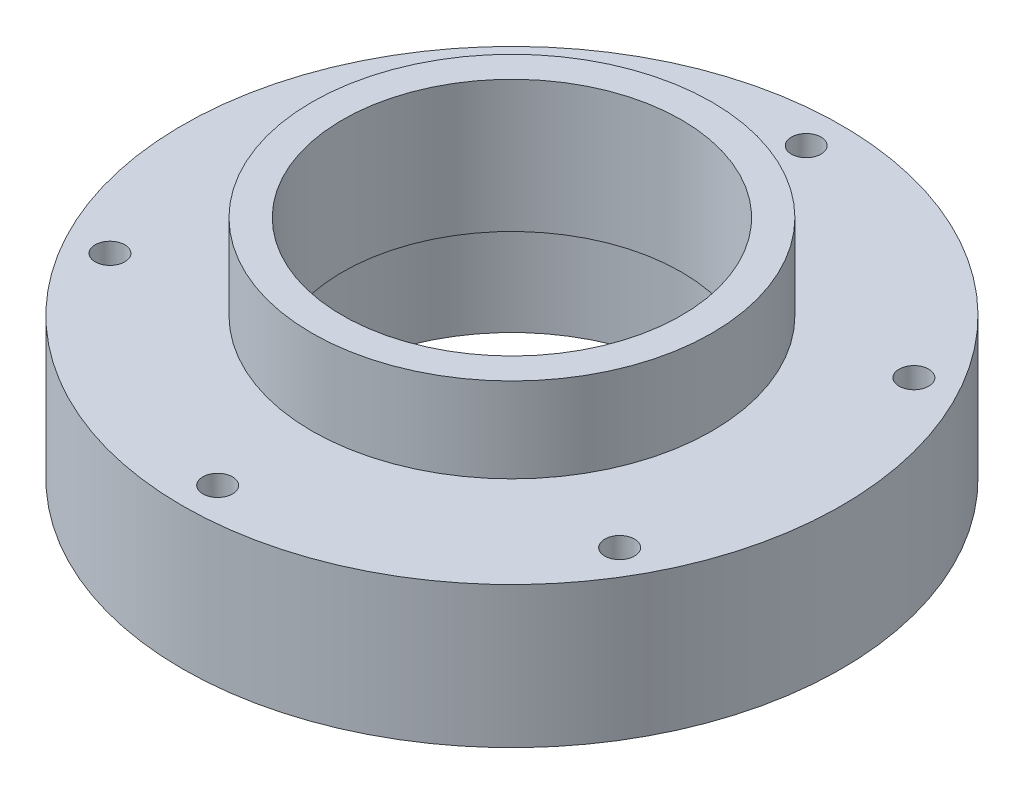
from build123d import *

# Parameters (mm, degrees)
SKETCH1_R                               = 17.78
BOSS_EXTRUDE1_DEPTH                     = 7.62
SKETCH2_R                               = 10.795
BOSS_EXTRUDE2_DEPTH                     = 4.572
M2X0_4_TAPPED_HOLE1_D                   = 1.6
CBORE_FOR_M5_HEX_HEAD_BOLT1_D           = 18.288
CBORE_FOR_M5_HEX_HEAD_BOLT1_CBORE_D     = 19.304
CBORE_FOR_M5_HEX_HEAD_BOLT1_CBORE_DEPTH = 5.08


with BuildPart() as part:
    # Sketch1 → Boss-Extrude1 (new body)
    with BuildSketch(Plane(origin=(0, 0, 0), x_dir=(1, 0, 0), z_dir=(0, 1, 0))):
        Circle(SKETCH1_R)
    extrude(amount=BOSS_EXTRUDE1_DEPTH)

    # Sketch2 → Boss-Extrude2 (add)
    with BuildSketch(Plane(origin=(0, 7.62, 0), x_dir=(1, 0, 0), z_dir=(0, 1, 0))):
        Circle(SKETCH2_R)
    extrude(amount=BOSS_EXTRUDE2_DEPTH)

    # M2x0.4 Tapped Hole1 (through all)
    with Locations(Plane(origin=(0, 0, 0), x_dir=(-1, 0, 0), z_dir=(0, -1, 0))):
        with Locations((0, 15.875), (13.748153285, 7.9375), (13.748153285, -7.9375), (0, -15.875), (-13.748153285, -7.9375), (-13.748153285, 7.9375)):
            Hole(M2X0_4_TAPPED_HOLE1_D / 2)

    # CBORE for M5 Hex Head Bolt1 (through all)
    with Locations(Plane(origin=(0, 0, 0), x_dir=(-1, 0, 0), z_dir=(0, -1, 0))):
        with Locations((0, 0)):
            CounterBoreHole(CBORE_FOR_M5_HEX_HEAD_BOLT1_D / 2, CBORE_FOR_M5_HEX_HEAD_BOLT1_CBORE_D / 2, CBORE_FOR_M5_HEX_HEAD_BOLT1_CBORE_DEPTH)


solid = part.part
